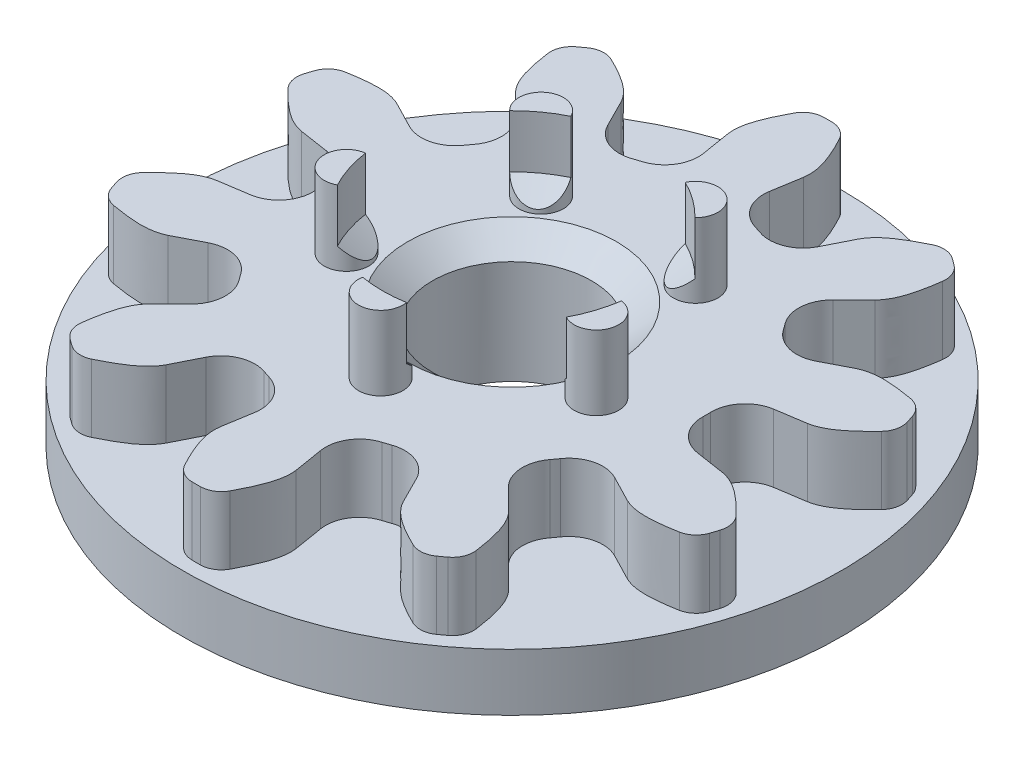
from build123d import *

# Parameters (mm, degrees)
SKETCH3_R                    = 3.7846
BOSS_EXTRUDE2_DEPTH          = 0.8128
CUT_EXTRUDE1_DEPTH           = 6.413597525
FILLET1_R                    = 0.4064
CIRPATTERN1_COUNT            = 10
FILLET1_OF_CIRPATTERN1_R     = 0.4064
SKETCH5_R                    = 0.9525
CENTER_HOLE_DEPTH            = 6.324028042
CENTER_HOLE_DEPTH_BACK       = 6.324028042
FILLET2_R                    = 0.254
SKETCH6_R                    = 0.2667
PEGS_DEPTH                   = 0.889
SKETCH7_R                    = 3.9497
SKETCH7_R_2                  = 1.5875
BOSS_EXTRUDE4_DEPTH          = 0.6858
CUT_EXTRUDE9_START           = 0.254
SKETCH6_5_R                  = 1.550000075
CUT_EXTRUDE9_DEPTH           = 25.4
CUT_EXTRUDE9_DRAFT           = -49.56
CUT_EXTRUDE9_OTHER_WAY_DEPTH = 6.783257189
SKETCH10_R                   = 0.5715
MOUNT_HOLES_DEPTH            = 0.508
SKETCH11_R                   = 1.5875
SKETCH11_R_2                 = 0.9525
FILL_CENTER_DEPTH            = 0.6858


with BuildPart() as part:
    # Sketch3 → Boss-Extrude2 (new body)
    with BuildSketch(Plane(origin=(0, 0, 0), x_dir=(1, 0, 0), z_dir=(0, 1, 0))):
        with Locations(Location((0, 0, 0), (0, 0, 270))):
            Circle(SKETCH3_R)
    extrude(amount=BOSS_EXTRUDE2_DEPTH)

    # Sketch4 → Cut-Extrude1 (cut, through all)
    with BuildSketch(Plane(origin=(0, 0.8128, 0), x_dir=(1, 0, 0), z_dir=(0, 1, 0))):
        with BuildLine():
            Line((2.301422024, -0.397689641), (3.031336714, -0.509151578))
            add(Edge.make_bspline(
                [(3.710887956, -1.046846357), (3.617311282, -0.93275427), (3.418286489, -0.716797693), (3.173582037, -0.533971616), (3.031336714, -0.509151578)],
                knots=[0.000617213, 0.000617213, 0.000617213, 0.000617213, 0.508760007, 1.016902802, 1.016902802, 1.016902802, 1.016902802], degree=3))
            ThreePointArc((3.710887956, -1.046846357), (3.85572, 0), (3.710887956, 1.046846357))
            add(Edge.make_bspline(
                [(3.031336714, 0.509151578), (3.173582037, 0.533971616), (3.418286489, 0.716797693), (3.617311282, 0.93275427), (3.710887956, 1.046846357)],
                knots=[0.000617213, 0.000617213, 0.000617213, 0.000617213, 0.508760007, 1.016902802, 1.016902802, 1.016902802, 1.016902802], degree=3))
            Line((3.031336714, 0.509151578), (2.301422024, 0.397689641))
            ThreePointArc((2.301422024, 0.397689641), (2.33553, 0), (2.301422024, -0.397689641))
        make_face()
    cut_extrude1 = extrude(amount=-CUT_EXTRUDE1_DEPTH, mode=Mode.SUBTRACT)

    # Fillet1
    fillet1_edges = [part.edges().sort_by_distance(p)[0] for p in [
        (2.301422024, 0.4064, 0.397689641),
        (2.301422024, 0.4064, -0.397689641),
    ]]
    fillet(fillet1_edges, radius=FILLET1_R)

    # CirPattern1: Cut-Extrude1 ×10 about axis
    cirpattern1_axis = Axis((0, 0.8128, 0), (0, -1, 0))
    for i in range(1, CIRPATTERN1_COUNT):
        add(cut_extrude1.rotate(cirpattern1_axis, i * 360 / CIRPATTERN1_COUNT), mode=Mode.SUBTRACT)

    # Fillet1 of CirPattern1
    fillet1_of_cirpattern1_edges = [part.edges().sort_by_distance(p)[0] for p in [
        (1.628133422, 0.4064, 1.674479603),
        (2.095645634, 0.4064, 1.031004247),
        (0.332953192, 0.4064, 2.31167527),
        (1.089403841, 0.4064, 2.065889555),
        (-1.089403841, 0.4064, 2.065889555),
        (-0.332953192, 0.4064, 2.31167527),
        (-2.095645634, 0.4064, 1.031004247),
        (-1.628133422, 0.4064, 1.674479603),
        (-2.301422024, 0.4064, -0.397689641),
        (-2.301422024, 0.4064, 0.397689641),
        (-1.628133422, 0.4064, -1.674479603),
        (-2.095645634, 0.4064, -1.031004247),
        (-0.332953192, 0.4064, -2.31167527),
        (-1.089403841, 0.4064, -2.065889555),
        (1.089403841, 0.4064, -2.065889555),
        (0.332953192, 0.4064, -2.31167527),
        (2.095645634, 0.4064, -1.031004247),
        (1.628133422, 0.4064, -1.674479603),
    ]]
    fillet(fillet1_of_cirpattern1_edges, radius=FILLET1_OF_CIRPATTERN1_R)

    # Sketch5 → center hole (cut, two sides)
    with BuildSketch(Plane(origin=(0, 0.8128, 0), x_dir=(1, 0, 0), z_dir=(0, 1, 0))) as center_hole_sk:
        with Locations(Location((0, 0, 0), (0, 0, 270))):
            Circle(SKETCH5_R)
    extrude(amount=CENTER_HOLE_DEPTH, mode=Mode.SUBTRACT)
    extrude(center_hole_sk.sketch, amount=-CENTER_HOLE_DEPTH_BACK, mode=Mode.SUBTRACT)

    # Fillet2
    fillet2_edges = [part.edges().sort_by_distance(p)[0] for p in [
        (2.380781464, 0.4064, -2.941951186),
        (2.062259914, 0.4063976, -3.173370638),
        (0.196857144, 0.4063976, -3.77947674),
        (-0.196857144, 0.4063979, -3.77947674),
        (-2.062259914, 0.4063979, -3.173370638),
        (-2.380781464, 0.4063982, -2.941951186),
        (-3.533663778, 0.4063982, -1.355144812),
        (-3.655328184, 0.4063985, -0.980700273),
        (-3.655328184, 0.4063985, 0.980700273),
        (-3.533663778, 0.4063988, 1.355144812),
        (-2.380781464, 0.4063988, 2.941951186),
        (-2.062259914, 0.4063991, 3.173370638),
        (-0.196857144, 0.4063991, 3.77947674),
        (0.196857144, 0.4063994, 3.77947674),
        (2.062259914, 0.4063994, 3.173370638),
        (2.380781464, 0.4063997, 2.941951186),
        (3.533663778, 0.4063997, 1.355144812),
        (3.655328184, 0.4064, 0.980700273),
        (3.655328184, 0.4064, -0.980700273),
        (3.533663778, 0.4064, -1.355144812),
    ]]
    fillet(fillet2_edges, radius=FILLET2_R)

    # Sketch6 → pegs (add)
    with BuildSketch(Plane(origin=(0, 0.8128, 0), x_dir=(1, 0, 0), z_dir=(0, 1, 0))):
        with Locations(Location((1.497723802, -0.486639963, 0), (0, 0, 270))):
            Circle(SKETCH6_R)
        with Locations(Location((0, -1.5748, 0), (0, 0, 270))):
            Circle(SKETCH6_R)
        with Locations(Location((-1.497723802, -0.486639963, 0), (0, 0, 270))):
            Circle(SKETCH6_R)
        with Locations(Location((-0.925644215, 1.274039963, 0), (0, 0, 270))):
            Circle(SKETCH6_R)
        with Locations(Location((0.925644215, 1.274039963, 0), (0, 0, 270))):
            Circle(SKETCH6_R)
    extrude(amount=PEGS_DEPTH)

    # Sketch7 → Boss-Extrude4 (add)
    with BuildSketch(Plane.XZ):
        with Locations(Location((0, 0, 0), (0, 0, 270))):
            Circle(SKETCH7_R)
        with Locations(Location((0, 0, 0), (0, 0, 270))):
            Circle(SKETCH7_R_2, mode=Mode.SUBTRACT)
    extrude(amount=BOSS_EXTRUDE4_DEPTH)


with BuildPart() as cut_extrude9_tool:
    # Sketch6_5 → Cut-Extrude9 (with draft: the straight prism first)
    with BuildSketch(Plane(origin=(0, 0.8128, 0), x_dir=(1, 0, 0), z_dir=(0, 1, 0)).offset(CUT_EXTRUDE9_START)):
        Circle(SKETCH6_5_R)
    extrude(amount=-CUT_EXTRUDE9_DEPTH)
    # Cut-Extrude9: the draft: its side faces are tilted about the plane it starts from
    cut_extrude9_sides = [cut_extrude9_tool.faces().sort_by_distance(p)[0] for p in [
        (-1.550000075, -11.6332, 0),
    ]]
    draft(cut_extrude9_sides, Plane(origin=(0, 0.8128, 0), x_dir=(1, 0, 0), z_dir=(0, 1, 0)).offset(CUT_EXTRUDE9_START), CUT_EXTRUDE9_DRAFT)


with BuildPart() as part_1:
    add(part.part)

    # Cut-Extrude9: cut by cut_extrude9_tool
    add(cut_extrude9_tool.part, mode=Mode.SUBTRACT)

    # Sketch6_5 → Cut-Extrude9 other way (cut)
    with BuildSketch(Plane(origin=(0, 0.8128, 0), x_dir=(1, 0, 0), z_dir=(0, 1, 0)).offset(CUT_EXTRUDE9_START)):
        Circle(SKETCH6_5_R)
    extrude(amount=CUT_EXTRUDE9_OTHER_WAY_DEPTH, mode=Mode.SUBTRACT)

    # Sketch10 → mount holes (cut)
    with BuildSketch(Plane.XZ.offset(0.6858)):
        with Locations(Location((3.1496, 0, 0), (0, 0, 270))):
            Circle(SKETCH10_R)
        with Locations(Location((0.973279925, -2.995447604, 0), (0, 0, 270))):
            Circle(SKETCH10_R)
        with Locations(Location((-2.548079925, -1.851288431, 0), (0, 0, 270))):
            Circle(SKETCH10_R)
        with Locations(Location((-2.548079925, 1.851288431, 0), (0, 0, 270))):
            Circle(SKETCH10_R)
        with Locations(Location((0.973279925, 2.995447604, 0), (0, 0, 270))):
            Circle(SKETCH10_R)
    extrude(amount=-MOUNT_HOLES_DEPTH, mode=Mode.SUBTRACT)

    # Sketch11 → fill center (add)
    with BuildSketch(Plane.XZ.offset(0.6858)):
        Circle(SKETCH11_R)
        with Locations(Location((0, 0, 0), (0, 0, 90))):
            Circle(SKETCH11_R_2, mode=Mode.SUBTRACT)
    extrude(amount=-FILL_CENTER_DEPTH)


solid = part_1.part
